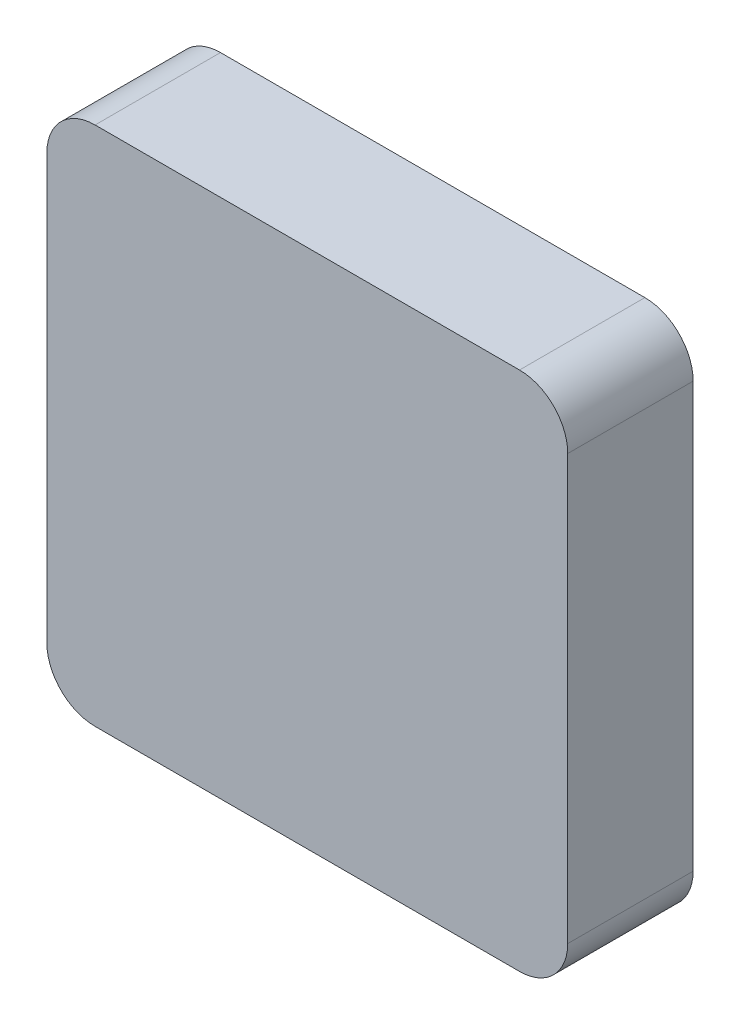
from build123d import *

# Parameters (mm, degrees)
ESQUISSE1_W        = 54
ESQUISSE1_H        = 54
BOSS_EXTRU_1_DEPTH = 13
CONG_2_R           = 5


with BuildPart() as part:
    # Esquisse1 → Boss.-Extru.1 (new body)
    with BuildSketch(Plane.XY):
        with Locations((27, -27)):
            Rectangle(ESQUISSE1_W, ESQUISSE1_H)
    extrude(amount=BOSS_EXTRU_1_DEPTH)

    # Congé2
    cong_2_edges = [part.edges().sort_by_distance(p)[0] for p in [
        (0, 0, 6.5),
        (54, 0, 6.5),
        (54, -54, 6.5),
        (0, -54, 6.5),
    ]]
    fillet(cong_2_edges, radius=CONG_2_R)


solid = part.part
